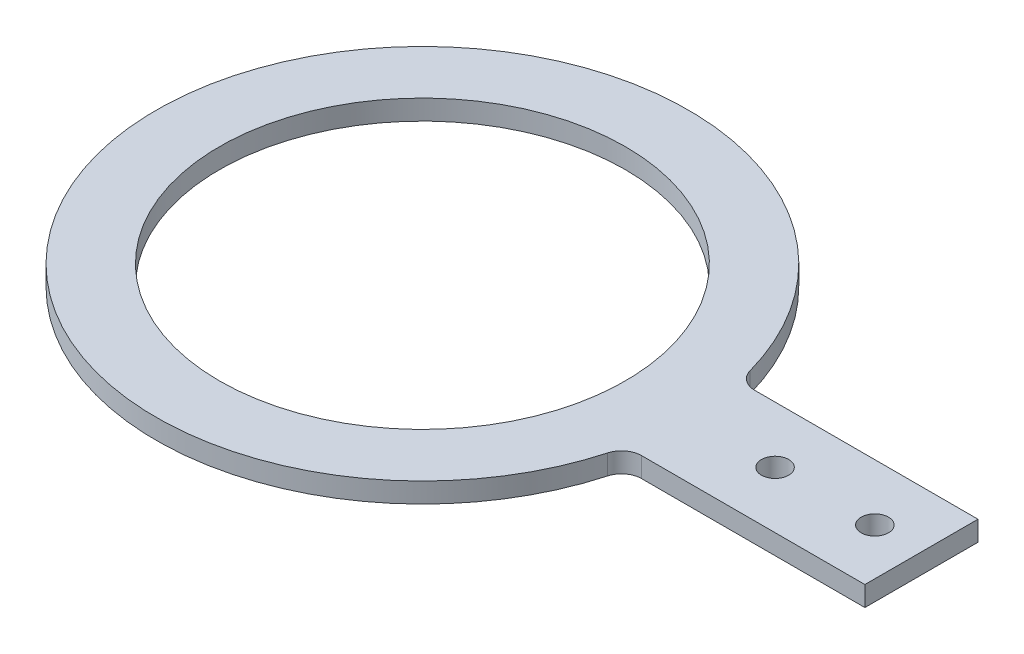
from build123d import *

# Parameters (mm, degrees)
SKETCH1_R           = 40
SKETCH1_R_2         = 30.5
BOSS_EXTRUDE1_DEPTH = 3
SKETCH2_W           = 40
SKETCH2_H           = 17
BOSS_EXTRUDE2_DEPTH = 3
SKETCH3_R           = 2.05
CUT_EXTRUDE1_DEPTH  = 4
FILLET1_R           = 3


with BuildPart() as part:
    # Sketch1 → Boss-Extrude1 (new body)
    with BuildSketch(Plane(origin=(0, 0, 0), x_dir=(1, 0, 0), z_dir=(0, 1, 0))):
        Circle(SKETCH1_R)
        Circle(SKETCH1_R_2, mode=Mode.SUBTRACT)
    extrude(amount=BOSS_EXTRUDE1_DEPTH)

    # Sketch2 → Boss-Extrude2 (add)
    with BuildSketch(Plane(origin=(0, 3, 0), x_dir=(1, 0, 0), z_dir=(0, 1, 0))):
        with Locations((55, 0)):
            Rectangle(SKETCH2_W, SKETCH2_H)
    extrude(amount=-BOSS_EXTRUDE2_DEPTH)

    # Sketch3 → Cut-Extrude1 (cut, through all)
    with BuildSketch(Plane(origin=(0, 3, 0), x_dir=(1, 0, 0), z_dir=(0, 1, 0))):
        with Locations((53, 0)):
            Circle(SKETCH3_R)
        with Locations((68, 0)):
            Circle(SKETCH3_R)
    extrude(amount=-CUT_EXTRUDE1_DEPTH, mode=Mode.SUBTRACT)

    # Fillet1
    fillet1_edges = [part.edges().sort_by_distance(p)[0] for p in [
        (39.086442662, 1.5, 8.5),
        (39.086442662, 1.5, -8.5),
    ]]
    fillet(fillet1_edges, radius=FILLET1_R)


solid = part.part
